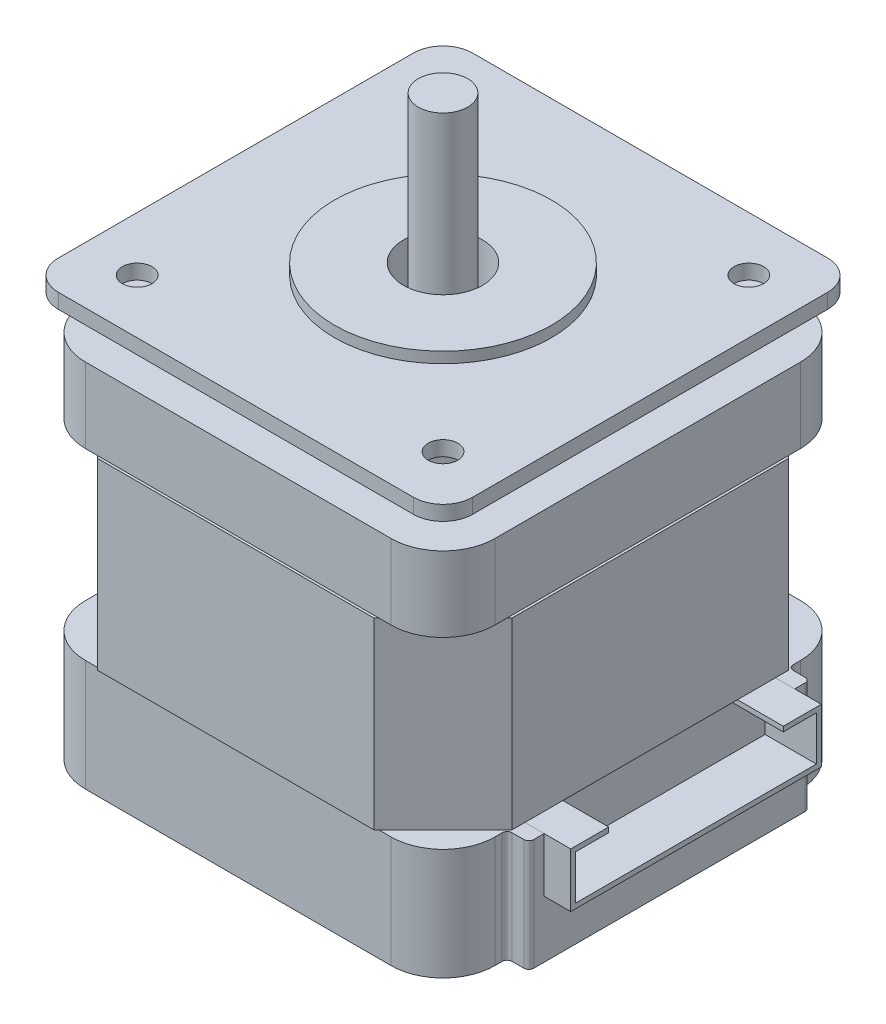
from build123d import *

# Parameters (mm, degrees)
SKETCH1_W            = 41.5
SKETCH1_H            = 41.5
BOSS_EXTRUDE1_DEPTH  = 11.3
SKETCH2_W            = 42
SKETCH2_H            = 42
BOSS_EXTRUDE2_DEPTH  = 18.6
CHAMFER1_SIZE        = 7
SKETCH6_W            = 41.5
SKETCH6_H            = 41.5
BOSS_EXTRUDE3_DEPTH  = 7.6
SKETCH7_R            = 17.5
BOSS_EXTRUDE4_DEPTH  = 3.5
SKETCH8_W            = 42
SKETCH8_H            = 42
BOSS_EXTRUDE5_DEPTH  = 1.5
FILLET1_R            = 5.25
FILLET2_R            = 5.25
FILLET3_R            = 3
SKETCH9_R            = 11
BOSS_EXTRUDE6_DEPTH  = 1.1
SKETCH4_R            = 1.5
SKETCH4_R_2          = 4
CUT_EXTRUDE1_DEPTH   = 44.6
SKETCH10_R           = 2.5
BOSS_EXTRUDE7_DEPTH  = 53
SKETCH11_W           = 28.5
SKETCH11_H           = 11.3
BOSS_EXTRUDE8_DEPTH  = 2.2
SKETCH12_W           = 25.4
SKETCH12_H           = 5.5
CUT_EXTRUDE2_DEPTH   = 3
FILLET4_R            = 0.5
SKETCH13_W           = 25.4
SKETCH13_H           = 5.5
BOSS_EXTRUDE9_DEPTH  = 0.5
BOSS_EXTRUDE10_DEPTH = 5.2


with BuildPart() as part:
    # Sketch1 → Boss-Extrude1 (new body)
    with BuildSketch(Plane(origin=(0, 0, 0), x_dir=(1, 0, 0), z_dir=(0, 1, 0))):
        Rectangle(SKETCH1_W, SKETCH1_H)
    extrude(amount=BOSS_EXTRUDE1_DEPTH)

    # Fillet1
    fillet1_edges = [part.edges().sort_by_distance(p)[0] for p in [
        (20.75, 5.65, 20.75),
        (-20.75, 5.65, 20.75),
        (-20.75, 5.65, -20.75),
        (20.75, 5.65, -20.75),
    ]]
    fillet(fillet1_edges, radius=FILLET1_R)


with BuildPart() as body_2:
    # Sketch2 → Boss-Extrude2 (new body)
    with BuildSketch(Plane(origin=(0, 11.3, 0), x_dir=(1, 0, 0), z_dir=(0, 1, 0))):
        Rectangle(SKETCH2_W, SKETCH2_H)
    extrude(amount=BOSS_EXTRUDE2_DEPTH)

    # Chamfer1
    chamfer1_edges = [body_2.edges().sort_by_distance(p)[0] for p in [
        (21, 20.6, 21),
        (-21, 20.6, 21),
        (-21, 20.6, -21),
        (21, 20.6, -21),
    ]]
    chamfer(chamfer1_edges, length=CHAMFER1_SIZE)


with BuildPart() as body_3:
    # Sketch6 → Boss-Extrude3 (new body)
    with BuildSketch(Plane(origin=(0, 29.9, 0), x_dir=(1, 0, 0), z_dir=(0, 1, 0))):
        Rectangle(SKETCH6_W, SKETCH6_H)
    extrude(amount=BOSS_EXTRUDE3_DEPTH)

    # Sketch7 → Boss-Extrude4 (add)
    with BuildSketch(Plane(origin=(0, 37.5, 0), x_dir=(1, 0, 0), z_dir=(0, 1, 0))):
        Circle(SKETCH7_R)
    extrude(amount=BOSS_EXTRUDE4_DEPTH)

    # Sketch8 → Boss-Extrude5 (add)
    with BuildSketch(Plane(origin=(0, 41, 0), x_dir=(1, 0, 0), z_dir=(0, 1, 0))):
        Rectangle(SKETCH8_W, SKETCH8_H)
    extrude(amount=BOSS_EXTRUDE5_DEPTH)

    # Fillet2
    fillet2_edges = [body_3.edges().sort_by_distance(p)[0] for p in [
        (20.75, 33.7, 20.75),
        (-20.75, 33.7, 20.75),
        (-20.75, 33.7, -20.75),
        (20.75, 33.7, -20.75),
    ]]
    fillet(fillet2_edges, radius=FILLET2_R)

    # Fillet3
    fillet3_edges = [body_3.edges().sort_by_distance(p)[0] for p in [
        (-21, 41.75, -21),
        (-21, 41.75, 21),
        (21, 41.75, 21),
        (21, 41.75, -21),
    ]]
    fillet(fillet3_edges, radius=FILLET3_R)

    # Sketch9 → Boss-Extrude6 (add)
    with BuildSketch(Plane(origin=(0, 42.5, 0), x_dir=(1, 0, 0), z_dir=(0, 1, 0))):
        Circle(SKETCH9_R)
    extrude(amount=BOSS_EXTRUDE6_DEPTH)


with BuildPart() as cut_extrude1_tool:
    # Sketch4 → Cut-Extrude1 (new body, through all)
    with BuildSketch(Plane.XZ):
        with Locations((-15.5, -15.5)):
            Circle(SKETCH4_R)
        with Locations((15.5, -15.5)):
            Circle(SKETCH4_R)
        with Locations((15.5, 15.5)):
            Circle(SKETCH4_R)
        with Locations((-15.5, 15.5)):
            Circle(SKETCH4_R)
        Circle(SKETCH4_R_2)
    extrude(amount=-CUT_EXTRUDE1_DEPTH)


with BuildPart() as part_1:
    add(part.part)

    # Cut-Extrude1: cut by cut_extrude1_tool
    add(cut_extrude1_tool.part, mode=Mode.SUBTRACT)

    # Sketch11 → Boss-Extrude8 (add)
    with BuildSketch(Plane(origin=(20.75, 0, 0), x_dir=(0, 0, -1), z_dir=(1, 0, 0))):
        with Locations((0, 5.65)):
            Rectangle(SKETCH11_W, SKETCH11_H)
    extrude(amount=BOSS_EXTRUDE8_DEPTH)

    # Sketch12 → Cut-Extrude2 (cut)
    with BuildSketch(Plane(origin=(22.95, 0, 0), x_dir=(0, 0, -1), z_dir=(1, 0, 0))):
        with Locations((0, 8.55)):
            Rectangle(SKETCH12_W, SKETCH12_H)
    extrude(amount=-CUT_EXTRUDE2_DEPTH, mode=Mode.SUBTRACT)

    # Fillet4
    fillet4_edges = [part_1.edges().sort_by_distance(p)[0] for p in [
        (20.75, 5.65, 14.25),
        (20.75, 5.65, -14.25),
        (22.95, 5.65, 14.25),
        (22.95, 5.65, -14.25),
    ]]
    fillet(fillet4_edges, radius=FILLET4_R)


with BuildPart() as body_2_1:
    add(body_2.part)

    # Cut-Extrude1: cut by cut_extrude1_tool
    add(cut_extrude1_tool.part, mode=Mode.SUBTRACT)


with BuildPart() as body_3_1:
    add(body_3.part)

    # Cut-Extrude1: cut by cut_extrude1_tool
    add(cut_extrude1_tool.part, mode=Mode.SUBTRACT)


with BuildPart() as body_4:
    # Sketch10 → Boss-Extrude7 (new body)
    with BuildSketch(Plane(origin=(0, 58.5, 0), x_dir=(-1, 0, 0), z_dir=(0, -1, 0))):
        Circle(SKETCH10_R)
    extrude(amount=BOSS_EXTRUDE7_DEPTH)


with BuildPart() as body_5:
    # Sketch13 → Boss-Extrude9 (new body)
    with BuildSketch(Plane(origin=(19.95, 0, 0), x_dir=(0, 0, -1), z_dir=(1, 0, 0))):
        with Locations((0, 8.55)):
            Rectangle(SKETCH13_W, SKETCH13_H)
    extrude(amount=BOSS_EXTRUDE9_DEPTH)

    # Sketch14 → Boss-Extrude10 (add)
    with BuildSketch(Plane(origin=(20.45, 0, 0), x_dir=(0, 0, -1), z_dir=(1, 0, 0))):
        Polygon((8.85, 11.3), (12.7, 11.3), (12.7, 5.8), (-12.7, 5.8), (-12.7, 11.3), (-8.85, 11.3), (-8.85, 10.8), (-12.2, 10.8), (-12.2, 6.3), (12.2, 6.3), (12.2, 10.8), (8.85, 10.8), align=None)
    extrude(amount=BOSS_EXTRUDE10_DEPTH)


solid = Compound([part_1.part, body_2_1.part, body_3_1.part, body_4.part, body_5.part])
